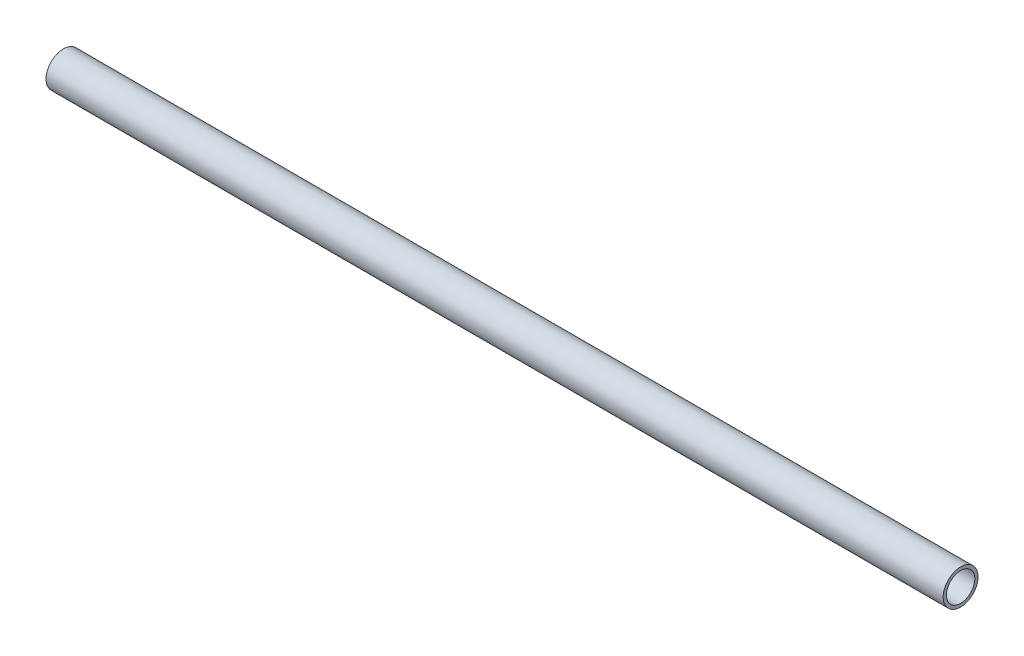
from build123d import *

# Parameters (mm, degrees)
SKETCH1_W = 496.930502708
SKETCH1_H = 1.778


with BuildPart() as part:
    # Sketch1 → Revolve1 (revolve)
    with BuildSketch(Plane.XY):
        with Locations((248.465251354, 8.763)):
            Rectangle(SKETCH1_W, SKETCH1_H)
    revolve(axis=Axis((0, 0, 0), (1, 0, 0)))


solid = part.part
